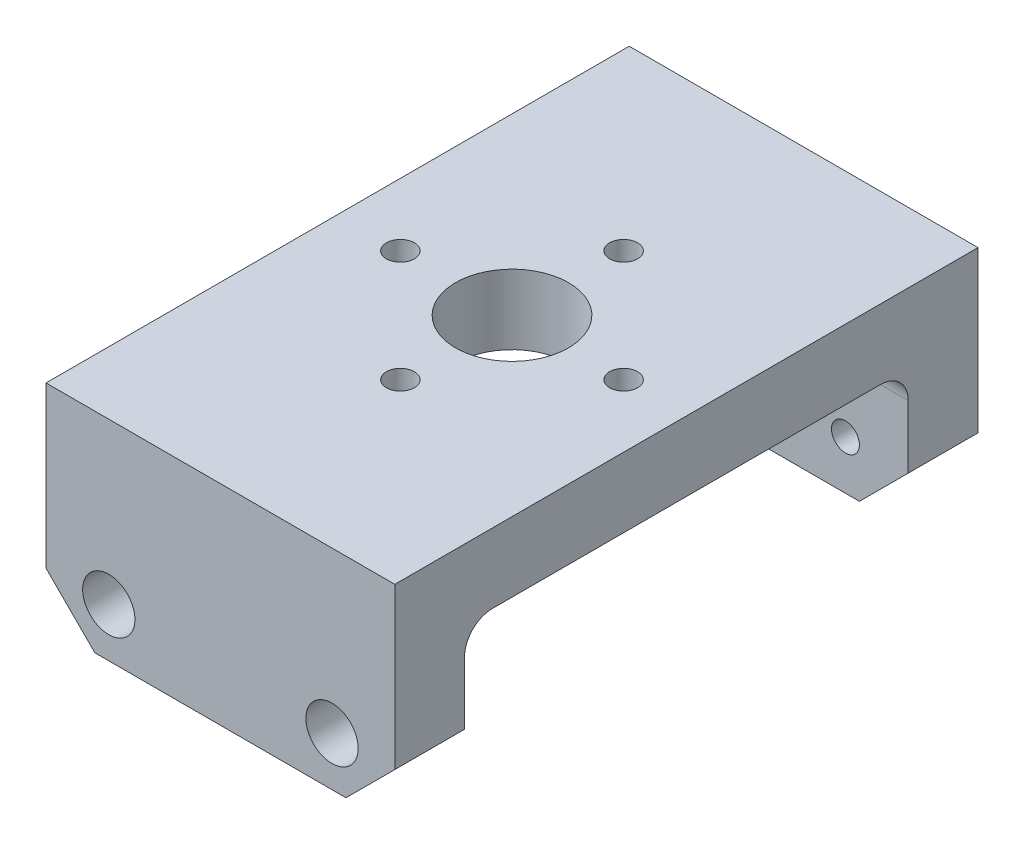
from build123d import *

# Parameters (mm, degrees)
SKETCH1_W           = 25
SKETCH1_H           = 15
SKETCH1_R           = 1
BOSS_EXTRUDE1_DEPTH = 5
SKETCH2_R           = 1.875
CUT_EXTRUDE1_DEPTH  = 3.3
CUT_EXTRUDE2_DEPTH  = 30.580398915
BOSS_EXTRUDE2_REACH = 48.949
SKETCH4_W           = 25
SKETCH4_H           = 5
SKETCH5_R           = 1
CUT_EXTRUDE3_DEPTH  = 50.721625074
SKETCH8_R           = 1.875
CUT_EXTRUDE4_DEPTH  = 1.25
CIRPATTERN1_COUNT   = 4
SKETCH9_R           = 4.05
CUT_EXTRUDE5_DEPTH  = 50.721625074
FILLET1_R           = 2
FILLET2_R           = 2


with BuildPart() as part:
    # Sketch1 → Boss-Extrude1 (new body)
    with BuildSketch(Plane.XY):
        with Locations((12.5, 7.5)):
            Rectangle(SKETCH1_W, SKETCH1_H)
        with Locations((4.5, 3.5)):
            Circle(SKETCH1_R, mode=Mode.SUBTRACT)
        with Locations((20.5, 3.5)):
            Circle(SKETCH1_R, mode=Mode.SUBTRACT)
    extrude(amount=BOSS_EXTRUDE1_DEPTH)

    # Sketch2 → Cut-Extrude1 (cut)
    with BuildSketch(Plane(origin=(0, 0, 0), x_dir=(-1, 0, 0), z_dir=(0, 0, -1))):
        with Locations((-20.5, 3.5)):
            Circle(SKETCH2_R)
        with Locations((-4.5, 3.5)):
            Circle(SKETCH2_R)
    extrude(amount=-CUT_EXTRUDE1_DEPTH, mode=Mode.SUBTRACT)

    # Sketch3 → Cut-Extrude2 (cut, through all)
    with BuildSketch(Plane(origin=(0, 0, 0), x_dir=(-1, 0, 0), z_dir=(0, 0, -1))):
        Polygon((0, 0), (-3.5, 0), (0, 3.5), align=None)
        Polygon((-21.5, 0), (-25, 0), (-25, 3.5), align=None)
    extrude(amount=-CUT_EXTRUDE2_DEPTH, mode=Mode.SUBTRACT)


with BuildPart() as body_2:
    # Mirror5: mirrored copy
    add(part.part.mirror(Plane.XY.offset(20.9)))


with BuildPart() as part_1:
    add(part.part)

    # Sketch4 → Boss-Extrude2 (add, up to next)
    with BuildSketch(Plane(origin=(0, 0, 36.8), x_dir=(-1, 0, 0), z_dir=(0, 0, -1)), mode=Mode.PRIVATE) as boss_extrude2_sk1:
        with Locations((-12.5, 12.5)):
            Rectangle(SKETCH4_W, SKETCH4_H)
    boss_extrude2_tool1 = extrude(boss_extrude2_sk1.sketch, amount=BOSS_EXTRUDE2_REACH, mode=Mode.PRIVATE) - part_1.part

    add(body_2.part)  # Boss-Extrude2 merges body 2
    add(boss_extrude2_tool1.solids().sort_by_distance((12.5, 12.5, 36.8))[0])

    # Sketch5 → Cut-Extrude3 (cut, through all)
    with BuildSketch(Plane.XZ.offset(-10)):
        with Locations((20.5, 20.9)):
            Circle(SKETCH5_R)
    cut_extrude3 = extrude(amount=-CUT_EXTRUDE3_DEPTH, mode=Mode.SUBTRACT)

    # Sketch8 → Cut-Extrude4 (cut)
    with BuildSketch(Plane.XZ.offset(-10)):
        with Locations((20.5, 20.9)):
            Circle(SKETCH8_R)
    cut_extrude4 = extrude(amount=-CUT_EXTRUDE4_DEPTH, mode=Mode.SUBTRACT)

    # CirPattern1: Cut-Extrude3, Cut-Extrude4 ×4 about axis
    cirpattern1_axis = Axis((12.5, -0.75, 20.9), (0, 1, 0))
    add([cut_extrude3.rotate(cirpattern1_axis, i * 360 / CIRPATTERN1_COUNT) for i in range(1, CIRPATTERN1_COUNT)], mode=Mode.SUBTRACT)
    add([cut_extrude4.rotate(cirpattern1_axis, i * 360 / CIRPATTERN1_COUNT) for i in range(1, CIRPATTERN1_COUNT)], mode=Mode.SUBTRACT)

    # Sketch9 → Cut-Extrude5 (cut, through all)
    with BuildSketch(Plane.XZ.offset(-10)):
        with Locations((12.5, 20.9)):
            Circle(SKETCH9_R)
    extrude(amount=-CUT_EXTRUDE5_DEPTH, mode=Mode.SUBTRACT)

    # Fillet1
    fillet1_edges = [part_1.edges().sort_by_distance(p)[0] for p in [
        (12.5, 10, 36.8),
    ]]
    fillet(fillet1_edges, radius=FILLET1_R)

    # Fillet2
    fillet2_edges = [part_1.edges().sort_by_distance(p)[0] for p in [
        (12.5, 10, 5),
    ]]
    fillet(fillet2_edges, radius=FILLET2_R)


solid = part_1.part
